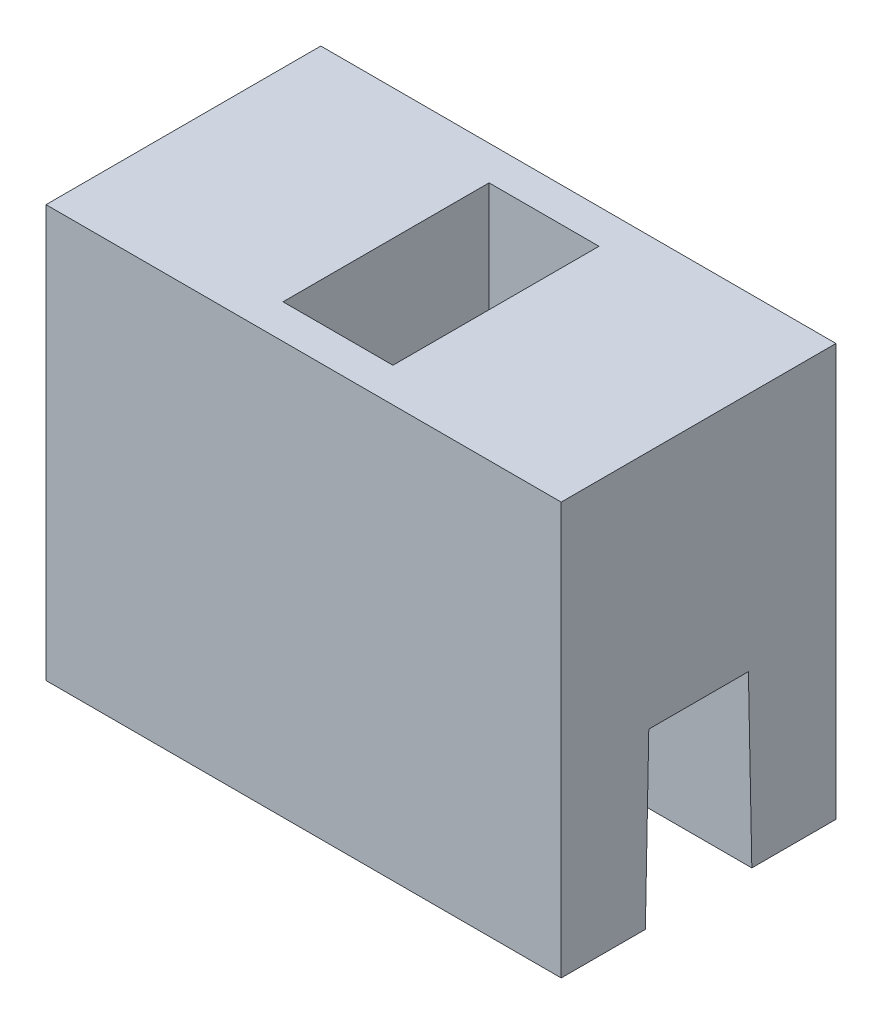
from build123d import *

# Parameters (mm, degrees)
BOSS_EXTRUDE1_DEPTH = 7.5
SKETCH2_W           = 3.2
SKETCH2_H           = 6
CUT_EXTRUDE1_DEPTH  = 5
FILLET1_R           = 1.5


with BuildPart() as part:
    # Sketch1 → Boss-Extrude1 (new body, symmetric)
    with BuildSketch(Plane(origin=(0, 0, 0), x_dir=(0, 0, -1), z_dir=(1, 0, 0))):
        Polygon((-1.55, 0), (-1.45, 5), (1.45, 5), (1.55, 0), (4, 0), (4, 12), (-4, 12), (-4, 0), align=None)
    extrude(amount=BOSS_EXTRUDE1_DEPTH, both=True)

    # Sketch2 → Cut-Extrude1 (cut)
    with BuildSketch(Plane(origin=(0, 12, 0), x_dir=(1, 0, 0), z_dir=(0, 1, 0))):
        Rectangle(SKETCH2_W, SKETCH2_H)
    extrude(amount=-CUT_EXTRUDE1_DEPTH, mode=Mode.SUBTRACT)

    # Fillet1
    fillet1_edges = [part.edges().sort_by_distance(p)[0] for p in [
        (1.6, 7, 0),
        (-1.6, 7, 0),
    ]]
    fillet(fillet1_edges, radius=FILLET1_R)


solid = part.part
